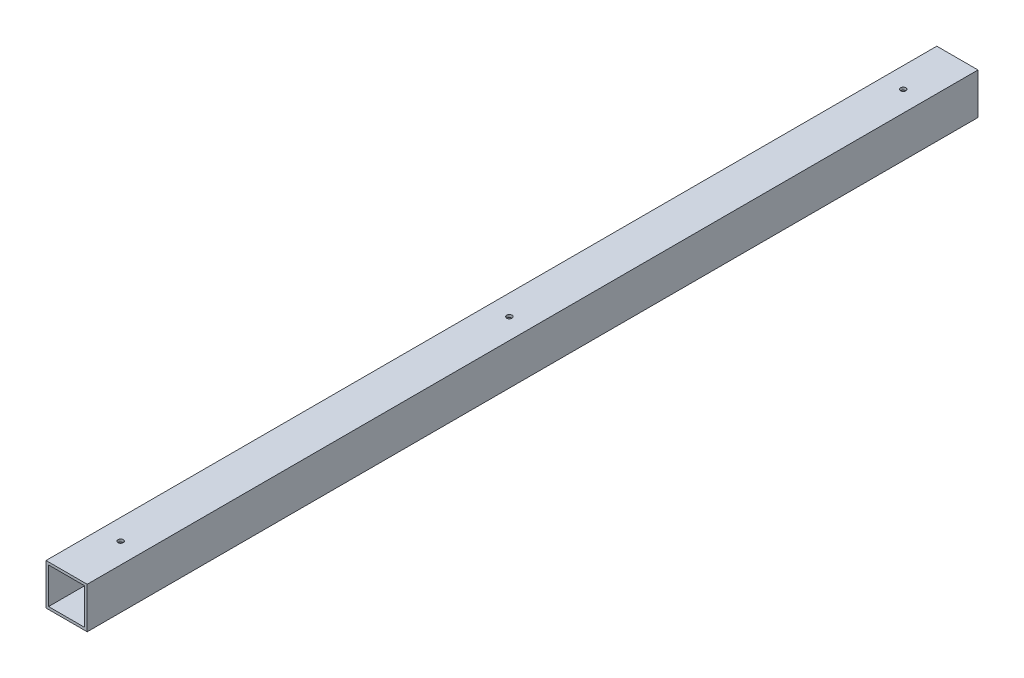
from build123d import *

# Parameters (mm, degrees)
SKETCH1_W           = 50.8
SKETCH1_H           = 50.8
SKETCH1_W_2         = 44.45
SKETCH1_H_2         = 44.45
BOSS_EXTRUDE1_DEPTH = 1098.55
SKETCH2_R           = 3.302
CUT_EXTRUDE1_DEPTH  = 50.8


with BuildPart() as part:
    # Sketch1 → Boss-Extrude1 (new body)
    with BuildSketch(Plane.XY):
        with Locations((2339.531183146, 25.4)):
            Rectangle(SKETCH1_W, SKETCH1_H)
        with Locations((2339.531183146, 25.4)):
            Rectangle(SKETCH1_W_2, SKETCH1_H_2, mode=Mode.SUBTRACT)
    extrude(amount=BOSS_EXTRUDE1_DEPTH)

    # Sketch2 → Cut-Extrude1 (cut)
    with BuildSketch(Plane(origin=(0, 50.8, 0), x_dir=(1, 0, 0), z_dir=(0, 1, 0))):
        with Locations((2339.531183146, -552.45)):
            Circle(SKETCH2_R)
        with Locations((2339.531183146, -1031.875)):
            Circle(SKETCH2_R)
        with Locations((2339.531183146, -66.802)):
            Circle(SKETCH2_R)
    extrude(amount=-CUT_EXTRUDE1_DEPTH, mode=Mode.SUBTRACT)


solid = part.part
